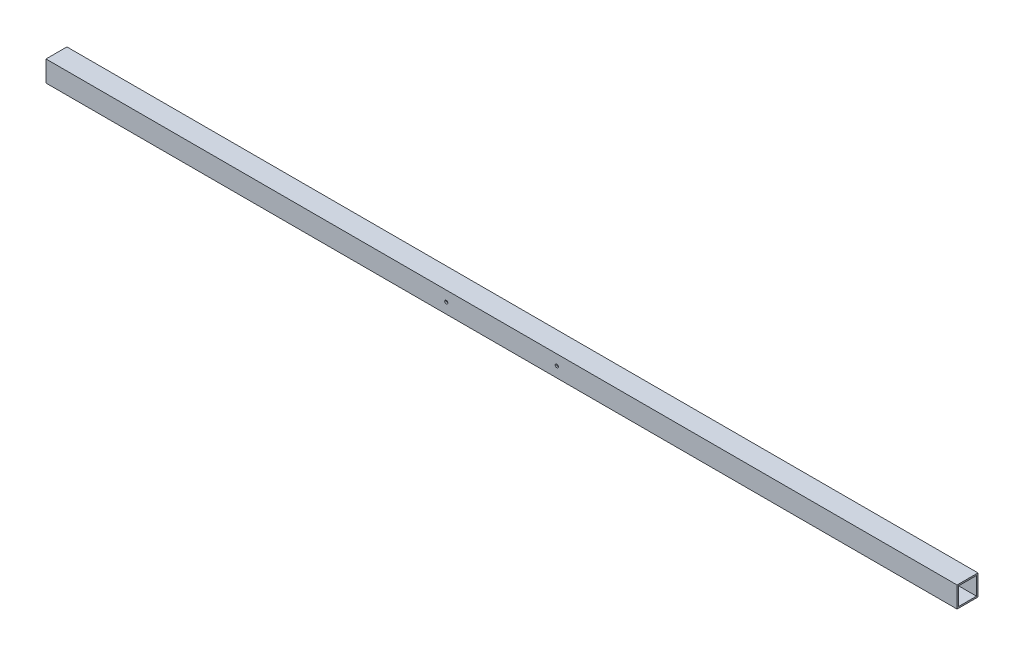
from build123d import *

# Parameters (mm, degrees)
SKETCH1_W                        = 44.45
SKETCH1_H                        = 44.45
SKETCH1_W_2                      = 38.1
SKETCH1_H_2                      = 38.1
BOSS_EXTRUDE1_DEPTH              = 1936.75
F_17_64_0_26563_DIAMETER_HOLE1_D = 6.747002


with BuildPart() as part:
    # Sketch1 → Boss-Extrude1 (new body)
    with BuildSketch(Plane(origin=(0, 0, 0), x_dir=(0, 0, -1), z_dir=(1, 0, 0))):
        with Locations((22.225, 22.225)):
            Rectangle(SKETCH1_W, SKETCH1_H)
        with Locations((22.225, 22.225)):
            Rectangle(SKETCH1_W_2, SKETCH1_H_2, mode=Mode.SUBTRACT)
    extrude(amount=BOSS_EXTRUDE1_DEPTH)

    # 17/64 (0.26563) Diameter Hole1 (through all)
    with Locations(Plane.XY):
        with Locations((850.9, 22.225), (1085.85, 22.225)):
            Hole(F_17_64_0_26563_DIAMETER_HOLE1_D / 2)


solid = part.part
